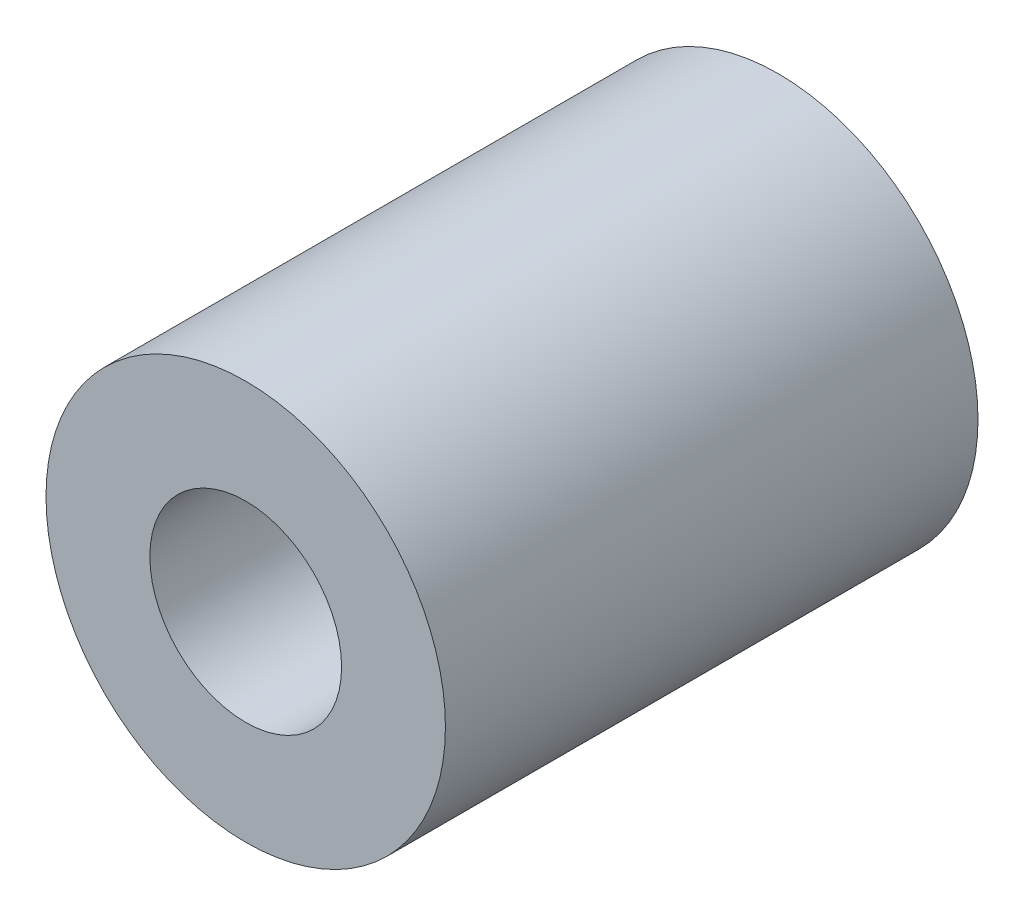
from build123d import *

# Parameters (mm, degrees)
SKETCH1_R      = 2.38125
SKETCH1_R_2    = 1.143
EXTRUDE1_DEPTH = 3.175


with BuildPart() as part:
    # Sketch1 → Extrude1 (new body, symmetric)
    with BuildSketch(Plane.XY):
        Circle(SKETCH1_R)
        Circle(SKETCH1_R_2, mode=Mode.SUBTRACT)
    extrude(amount=EXTRUDE1_DEPTH, both=True)


solid = part.part
